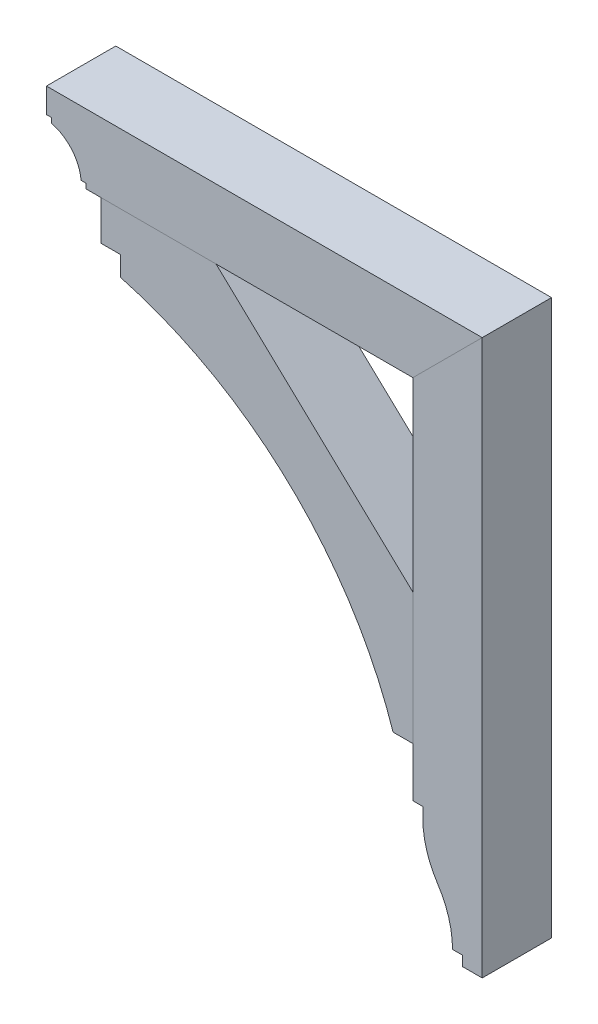
from build123d import *

# Parameters (mm, degrees)
BOSS_EXTRUDE1_DEPTH = 44.45
BOSS_EXTRUDE2_DEPTH = 44.45
BOSS_EXTRUDE3_DEPTH = 44.45


with BuildPart() as part:
    # Sketch1 → Boss-Extrude1 (new body, symmetric)
    with BuildSketch(Plane.XY):
        with BuildLine():
            Line((-229.368776984, 337.185), (-229.368776984, 343.535))
            Line((-229.368776984, 343.535), (-235.718776984, 343.535))
            Line((-235.718776984, 343.535), (-235.718776984, 375.285))
            Line((-235.718776984, 375.285), (323.081223016, 375.285))
            Line((323.081223016, 375.285), (234.181223016, 286.385))
            Line((234.181223016, 286.385), (-184.918776984, 286.385))
            Line((-184.918776984, 286.385), (-184.918776984, 292.735))
            Line((-184.918776984, 292.735), (-191.268776984, 292.735))
            ThreePointArc((-191.268776984, 292.735), (-203.260423906, 321.010016924), (-229.368776984, 337.185))
        make_face()
    extrude(amount=BOSS_EXTRUDE1_DEPTH, both=True)


with BuildPart() as body_2:
    # Sketch1_3 → Boss-Extrude2 (new body, symmetric)
    with BuildSketch(Plane.XY):
        with BuildLine():
            Line((234.181223016, 48.26), (-18.231276984, 286.385))
            Line((-18.231276984, 286.385), (-165.868776984, 286.385))
            Line((-165.868776984, 286.385), (-165.868776984, 235.585))
            Line((-165.868776984, 235.585), (-140.468776984, 235.585))
            Line((-140.468776984, 235.585), (-140.468776984, 210.185))
            ThreePointArc((-140.468776984, 210.185), (75.677544074, 89.001781889), (208.781223016, -120.015))
            Line((208.781223016, -120.015), (234.181223016, -120.015))
            Line((234.181223016, -120.015), (234.181223016, 48.26))
        make_face()
    extrude(amount=BOSS_EXTRUDE2_DEPTH, both=True)


with BuildPart() as body_3:
    # Sketch1_4 → Boss-Extrude3 (new body, symmetric)
    with BuildSketch(Plane.XY):
        with BuildLine():
            Line((323.081223016, -335.915), (323.081223016, 375.285))
            Line((323.081223016, 375.285), (234.181223016, 286.385))
            Line((234.181223016, 286.385), (234.181223016, -183.515))
            Line((234.181223016, -183.515), (246.881223016, -183.515))
            Line((246.881223016, -183.515), (246.881223016, -196.215))
            ThreePointArc((246.881223016, -196.215), (251.768629387, -229.515028089), (266.018608337, -260.006284404))
            ThreePointArc((266.018608337, -260.006284404), (280.138450492, -290.219081757), (284.981223016, -323.215))
            Line((284.981223016, -323.215), (297.681223016, -323.215))
            Line((297.681223016, -323.215), (297.681223016, -335.915))
            Line((297.681223016, -335.915), (323.081223016, -335.915))
        make_face()
    extrude(amount=BOSS_EXTRUDE3_DEPTH, both=True)


solid = Compound([part.part, body_2.part, body_3.part])
